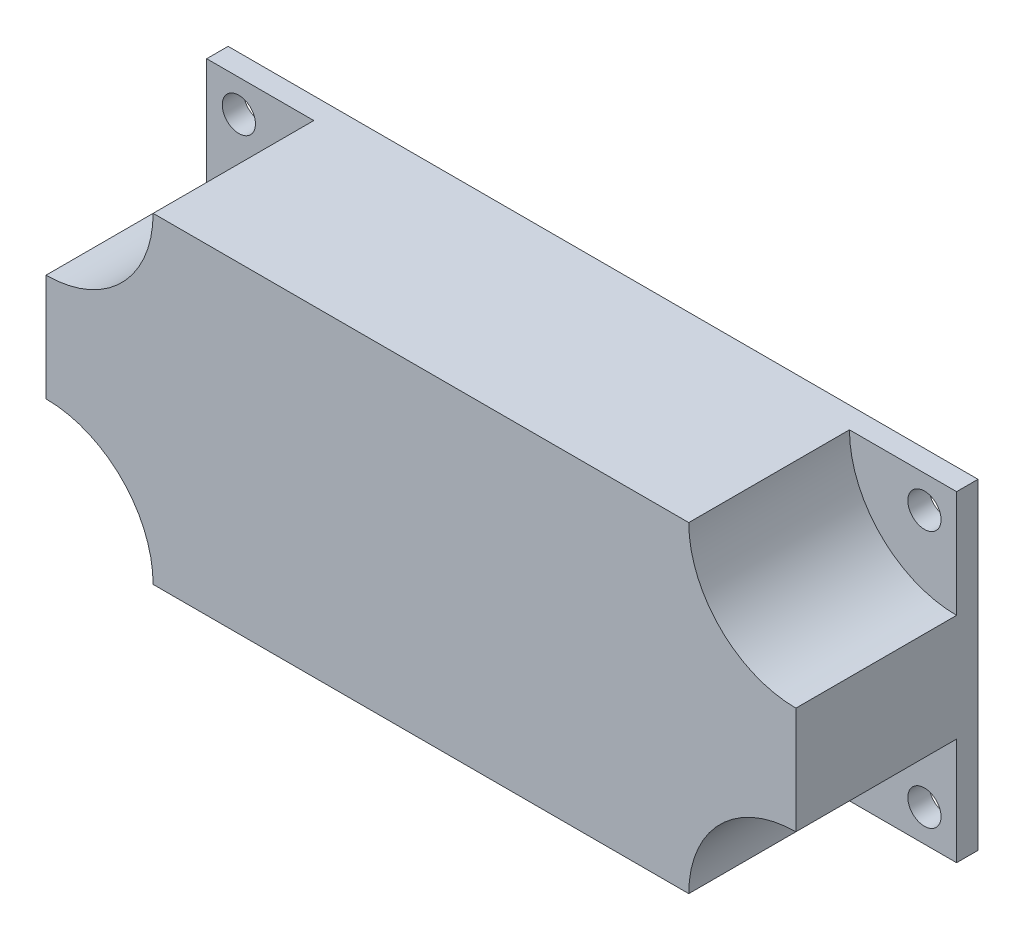
from build123d import *

# Parameters (mm, degrees)
SKETCH1_W           = 70
SKETCH1_H           = 30
SKETCH1_R           = 1.55
BOSS_EXTRUDE1_DEPTH = 17
SKETCH2_R           = 1.55
CUT_EXTRUDE1_DEPTH  = 15


with BuildPart() as part:
    # Sketch1 → Boss-Extrude1 (new body)
    with BuildSketch(Plane.XY):
        Rectangle(SKETCH1_W, SKETCH1_H)
        with Locations((-32, 12)):
            Circle(SKETCH1_R, mode=Mode.SUBTRACT)
        with Locations((32, 12)):
            Circle(SKETCH1_R, mode=Mode.SUBTRACT)
        with Locations((32, -12)):
            Circle(SKETCH1_R, mode=Mode.SUBTRACT)
        with Locations((-32, -12)):
            Circle(SKETCH1_R, mode=Mode.SUBTRACT)
    extrude(amount=BOSS_EXTRUDE1_DEPTH)

    # Sketch2 → Cut-Extrude1 (cut)
    with BuildSketch(Plane.XY.offset(17)):
        with BuildLine():
            Line((-35, 15), (-35, 5))
            ThreePointArc((-35, 5), (-27.928932188, 7.928932188), (-25, 15))
            Line((-25, 15), (-35, 15))
        make_face()
        with Locations((-32, 12)):
            Circle(SKETCH2_R, mode=Mode.SUBTRACT)
        with BuildLine():
            Line((35, 15), (25, 15))
            ThreePointArc((25, 15), (27.928932188, 7.928932188), (35, 5))
            Line((35, 5), (35, 15))
        make_face()
        with Locations((32, 12)):
            Circle(SKETCH2_R, mode=Mode.SUBTRACT)
        with BuildLine():
            ThreePointArc((35, -5), (27.928932188, -7.928932188), (25, -15))
            Line((25, -15), (35, -15))
            Line((35, -15), (35, -5))
        make_face()
        with Locations((32, -12)):
            Circle(SKETCH2_R, mode=Mode.SUBTRACT)
        with BuildLine():
            ThreePointArc((-25, -15), (-27.928932188, -7.928932188), (-35, -5))
            Line((-35, -5), (-35, -15))
            Line((-35, -15), (-25, -15))
        make_face()
        with Locations((-32, -12)):
            Circle(SKETCH2_R, mode=Mode.SUBTRACT)
    extrude(amount=-CUT_EXTRUDE1_DEPTH, mode=Mode.SUBTRACT)


solid = part.part
